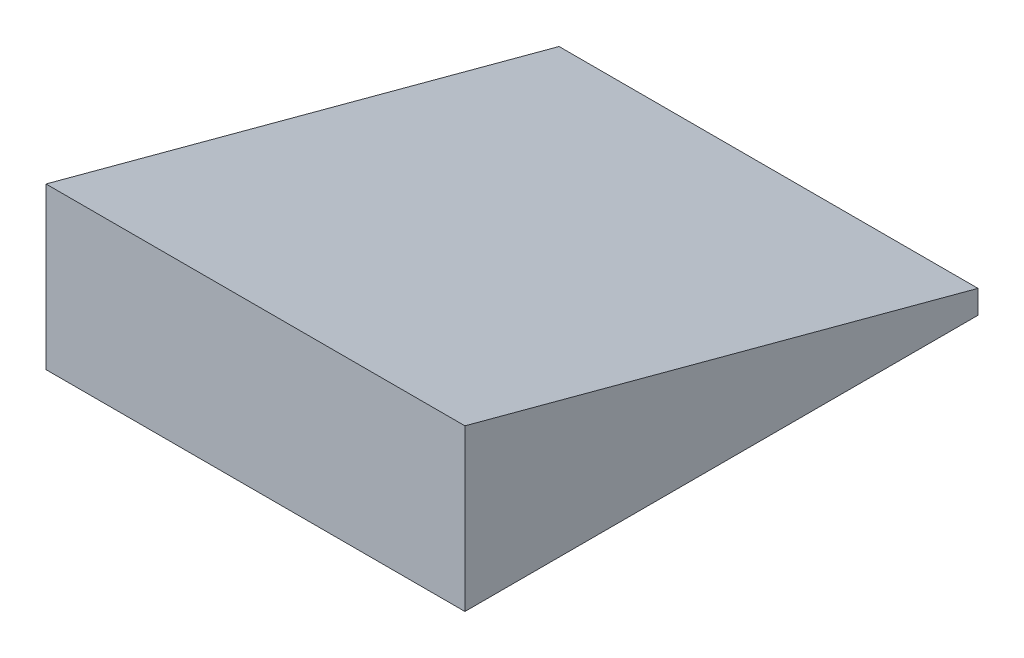
from build123d import *

# Parameters (mm, degrees)
SKETCH_1_W          = 179.63
SKETCH_1_H          = 220
EXTRUDE_1_DEPTH     = 5
SKETCH_2_W          = 179.63
SKETCH_2_H          = 220
EXTRUDE_2_DEPTH     = 103
CUT_EXTRUDE_1_DEPTH = 375


with BuildPart() as part:
    # Эскиз1 → Бобышка-Вытянуть1 (new body)
    with BuildSketch(Plane(origin=(0, 0, 0), x_dir=(1, 0, 0), z_dir=(0, 1, 0))):
        with Locations((-85.713003719, 94.130447377)):
            Rectangle(SKETCH_1_W, SKETCH_1_H)
    extrude(amount=EXTRUDE_1_DEPTH)

    # Эскиз2 → Бобышка-Вытянуть2 (add)
    with BuildSketch(Plane(origin=(0, 5, 0), x_dir=(1, 0, 0), z_dir=(0, 1, 0))):
        with Locations((-85.713003719, 94.130447377)):
            Rectangle(SKETCH_2_W, SKETCH_2_H)
    extrude(amount=EXTRUDE_2_DEPTH)

    # Эскиз3 → Вырез-Вытянуть1 (cut)
    with BuildSketch(Plane(origin=(4.101996281, 0, 0), x_dir=(0, 0, -1), z_dir=(1, 0, 0))):
        Polygon((-5.789329855, 66.247834785), (204.130447377, 10), (204.130447377, 108), (-15.869552623, 108), (-15.869552623, 68.948822335), align=None)
    extrude(amount=-CUT_EXTRUDE_1_DEPTH, mode=Mode.SUBTRACT)


solid = part.part
